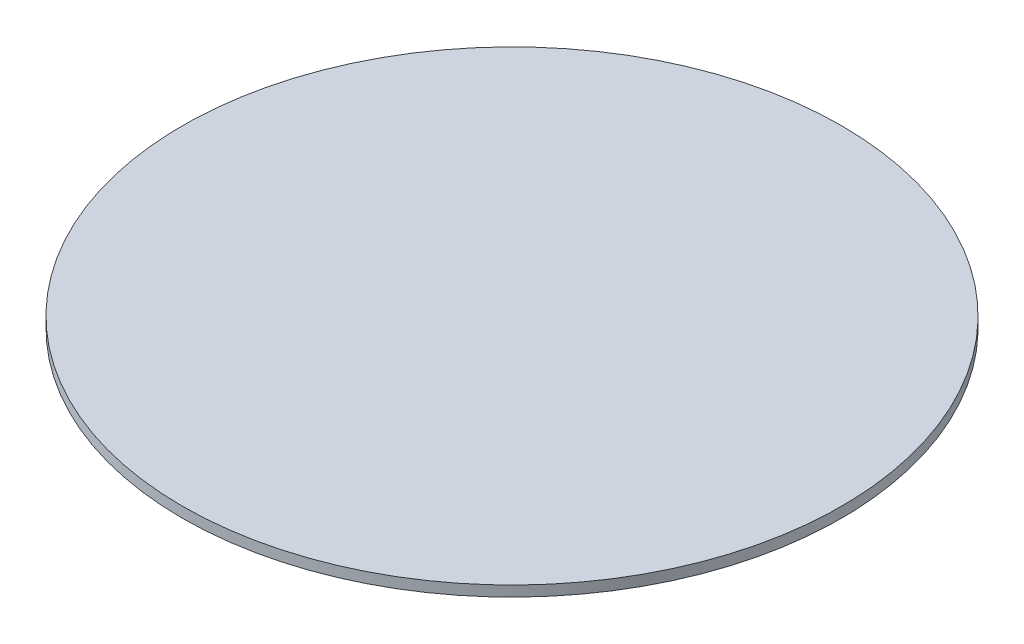
from build123d import *

# Parameters (mm, degrees)
SKETCH1_R           = 1200
BOSS_EXTRUDE1_DEPTH = 38.1


with BuildPart() as part:
    # Sketch1 → Boss-Extrude1 (new body)
    with BuildSketch(Plane(origin=(0, 0, 0), x_dir=(1, 0, 0), z_dir=(0, 1, 0))):
        Circle(SKETCH1_R)
    extrude(amount=BOSS_EXTRUDE1_DEPTH)


solid = part.part
